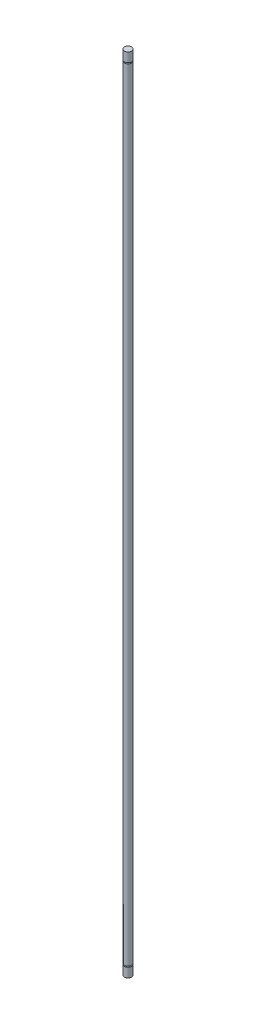
from build123d import *

# Parameters (mm, degrees)
SKETCH1_R           = 2.38125
BOSS_EXTRUDE1_DEPTH = 260.35
SKETCH8_W           = 1.6637
SKETCH8_H           = 0.635


with BuildPart() as part:
    # Sketch1 → Boss-Extrude1 (new body, symmetric)
    with BuildSketch(Plane(origin=(0, 0, 0), x_dir=(1, 0, 0), z_dir=(0, 1, 0))):
        Circle(SKETCH1_R)
    extrude(amount=BOSS_EXTRUDE1_DEPTH, both=True)

    # Cut-Sweep1: sweep along a path in Sketch7
    with BuildLine(Plane(origin=(0, -254, 0), x_dir=(-1, 0, 0), z_dir=(0, -1, 0))) as cut_sweep1_path:
        CenterArc((0, 0), 2.38125, 0, 360)
    # Sketch8 → Cut-Sweep1 (sweep, cut)
    with BuildSketch(Plane(origin=(0, 0, 0), x_dir=(0, 0, -1), z_dir=(1, 0, 0))):
        with Locations((2.38125, -254)):
            Rectangle(SKETCH8_W, SKETCH8_H)
    cut_sweep1 = sweep(path=cut_sweep1_path.line, mode=Mode.SUBTRACT)

    # Mirror1: Cut-Sweep1 across plane
    add(cut_sweep1.mirror(Plane.ZX), mode=Mode.SUBTRACT)


solid = part.part
